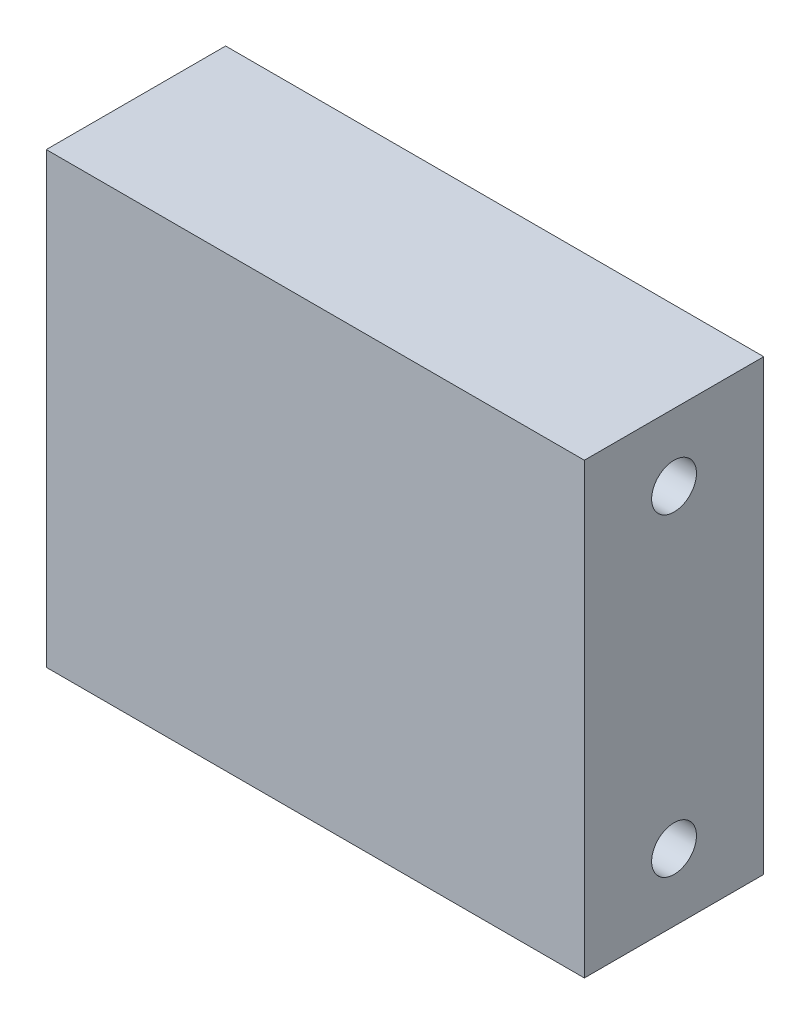
from build123d import *

# Parameters (mm, degrees)
SKETCH1_W           = 152.4
SKETCH1_H           = 50.8
BOSS_EXTRUDE1_DEPTH = 127
SKETCH3_R           = 6.35
CUT_EXTRUDE1_DEPTH  = 153.4


with BuildPart() as part:
    # Sketch1 → Boss-Extrude1 (new body)
    with BuildSketch(Plane(origin=(0, 0, 0), x_dir=(1, 0, 0), z_dir=(0, 1, 0))):
        with Locations((76.2, 25.4)):
            Rectangle(SKETCH1_W, SKETCH1_H)
    extrude(amount=BOSS_EXTRUDE1_DEPTH)

    # Sketch3 → Cut-Extrude1 (cut, through all)
    with BuildSketch(Plane.ZY):
        with Locations((-25.4, 19.05)):
            Circle(SKETCH3_R)
        with Locations((-25.4, 107.95)):
            Circle(SKETCH3_R)
    extrude(amount=-CUT_EXTRUDE1_DEPTH, mode=Mode.SUBTRACT)


solid = part.part
